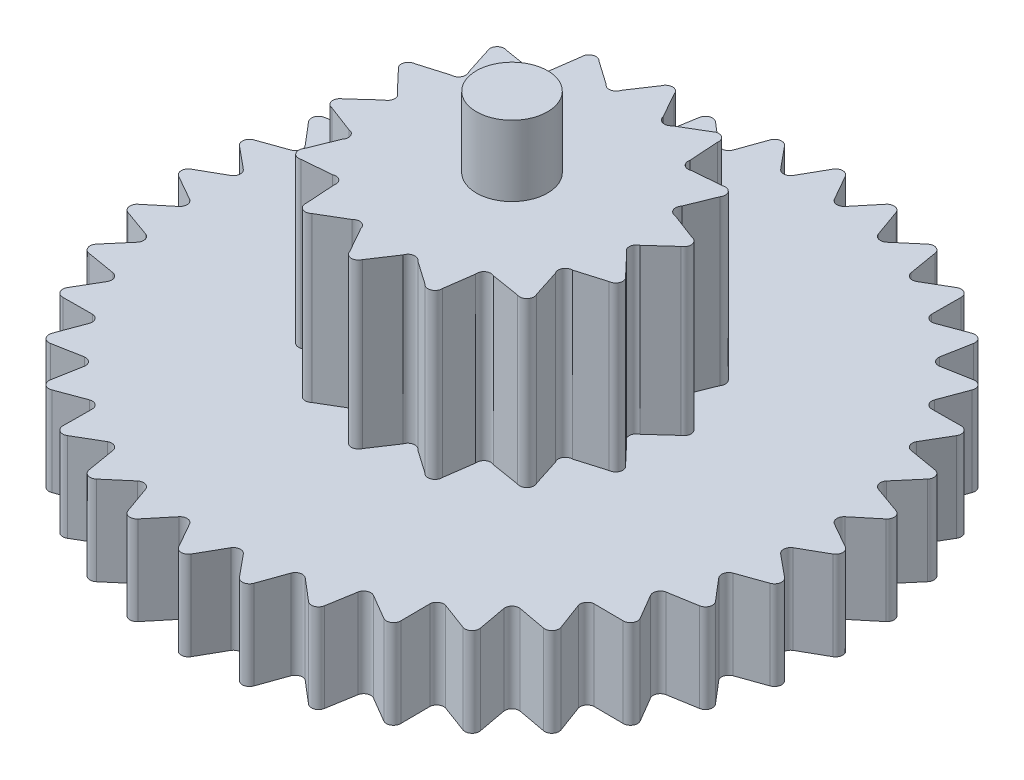
from build123d import *

# Parameters (mm, degrees)
BOSS_EXTRUDE1_DEPTH      = 2.5
SKETCH2_R                = 1
BOSS_EXTRUDE2_DEPTH      = 7.1
SKETCH3_R                = 1
BOSS_EXTRUDE3_DEPTH      = 9.08
BOSS_EXTRUDE3_DEPTH_BACK = 2.6
FILLET1_R                = 1


with BuildPart() as part:
    # Sketch1 → Boss-Extrude1 (new body)
    with BuildSketch(Plane(origin=(0, 0, 0), x_dir=(1, 0, 0), z_dir=(0, 1, 0))):
        with BuildLine():
            Line((1.42370209, 9.08258892), (0.900959127, 8.450813806))
            ThreePointArc((0.900959127, 8.450813806), (0.825205502, 8.397364753), (0.733489057, 8.383818287))
            ThreePointArc((0.733489057, 8.383818287), (0.64551831, 8.413085345), (0.580196884, 8.478876866))
            Line((0.580196884, 8.478876866), (0.175102158, 9.191827259))
            ThreePointArc((0.175102158, 9.191827259), (0, 9.295187545), (-0.175102158, 9.191827259))
            Line((-0.175102158, 9.191827259), (-0.580196884, 8.478876866))
            ThreePointArc((-0.580196884, 8.478876866), (-0.64551831, 8.413085345), (-0.733489057, 8.383818287))
            ThreePointArc((-0.733489057, 8.383818287), (-0.825205502, 8.397364753), (-0.900959127, 8.450813806))
            Line((-0.900959127, 8.450813806), (-1.42370209, 9.08258892))
            ThreePointArc((-1.42370209, 9.08258892), (-1.614092378, 9.15397276), (-1.768586015, 9.021776578))
            Line((-1.768586015, 9.021776578), (-2.043723906, 8.249313543))
            ThreePointArc((-2.043723906, 8.249313543), (-2.096628375, 8.173178596), (-2.178180478, 8.12908021))
            ThreePointArc((-2.178180478, 8.12908021), (-2.270855863, 8.126494482), (-2.35473995, 8.165977045))
            Line((-2.35473995, 8.165977045), (-2.979247871, 8.697380712))
            ThreePointArc((-2.979247871, 8.697380712), (-3.179141376, 8.734619145), (-3.308332282, 8.577603782))
            Line((-3.308332282, 8.577603782), (-3.445153411, 7.769099002))
            ThreePointArc((-3.445153411, 7.769099002), (-3.484033448, 7.684933952), (-3.556688986, 7.627344145))
            ThreePointArc((-3.556688986, 7.627344145), (-3.647507417, 7.608704788), (-3.736973192, 7.633021204))
            Line((-3.736973192, 7.633021204), (-4.444270713, 8.047906992))
            ThreePointArc((-4.444270713, 8.047906992), (-4.647593772, 8.049868547), (-4.747556546, 7.872804835))
            Line((-4.747556546, 7.872804835), (-4.741903674, 7.05282432))
            ThreePointArc((-4.741903674, 7.05282432), (-4.765577928, 6.963186478), (-4.8271293, 6.893855088))
            ThreePointArc((-4.8271293, 6.893855088), (-4.913331304, 6.85972845), (-5.005660395, 6.868139875))
            Line((-5.005660395, 6.868139875), (-5.774256638, 7.153901691))
            ThreePointArc((-5.774256638, 7.153901691), (-5.974831384, 7.120526766), (-6.042528707, 6.928794696))
            Line((-6.042528707, 6.928794696), (-5.894573592, 6.122253139))
            ThreePointArc((-5.894573592, 6.122253139), (-5.902322733, 6.029866106), (-5.950899733, 5.950899733))
            ThreePointArc((-5.950899733, 5.950899733), (-6.029866106, 5.902322733), (-6.122253139, 5.894573592))
            Line((-6.122253139, 5.894573592), (-6.928794696, 6.042528707))
            ThreePointArc((-6.928794696, 6.042528707), (-7.120526766, 5.974831384), (-7.153901691, 5.774256638))
            Line((-7.153901691, 5.774256638), (-6.868139875, 5.005660395))
            ThreePointArc((-6.868139875, 5.005660395), (-6.85972845, 4.913331304), (-6.893855088, 4.8271293))
            ThreePointArc((-6.893855088, 4.8271293), (-6.963186478, 4.765577928), (-7.05282432, 4.741903674))
            Line((-7.05282432, 4.741903674), (-7.872804835, 4.747556546))
            ThreePointArc((-7.872804835, 4.747556546), (-8.049868547, 4.647593772), (-8.047906992, 4.444270713))
            Line((-8.047906992, 4.444270713), (-7.633021204, 3.736973192))
            ThreePointArc((-7.633021204, 3.736973192), (-7.608704788, 3.647507417), (-7.627344145, 3.556688986))
            ThreePointArc((-7.627344145, 3.556688986), (-7.684933952, 3.484033448), (-7.769099002, 3.445153411))
            Line((-7.769099002, 3.445153411), (-8.577603782, 3.308332282))
            ThreePointArc((-8.577603782, 3.308332282), (-8.734619145, 3.179141376), (-8.697380712, 2.979247871))
            Line((-8.697380712, 2.979247871), (-8.165977045, 2.35473995))
            ThreePointArc((-8.165977045, 2.35473995), (-8.126494482, 2.270855863), (-8.12908021, 2.178180478))
            ThreePointArc((-8.12908021, 2.178180478), (-8.173178596, 2.096628375), (-8.249313543, 2.043723906))
            Line((-8.249313543, 2.043723906), (-9.021776578, 1.768586015))
            ThreePointArc((-9.021776578, 1.768586015), (-9.15397276, 1.614092378), (-9.08258892, 1.42370209))
            Line((-9.08258892, 1.42370209), (-8.450813806, 0.900959127))
            ThreePointArc((-8.450813806, 0.900959127), (-8.397364753, 0.825205502), (-8.383818287, 0.733489057))
            ThreePointArc((-8.383818287, 0.733489057), (-8.413085345, 0.64551831), (-8.478876866, 0.580196884))
            Line((-8.478876866, 0.580196884), (-9.191827259, 0.175102158))
            ThreePointArc((-9.191827259, 0.175102158), (-9.295187545, 0), (-9.191827259, -0.175102158))
            Line((-9.191827259, -0.175102158), (-8.478876866, -0.580196884))
            ThreePointArc((-8.478876866, -0.580196884), (-8.413085345, -0.64551831), (-8.383818287, -0.733489057))
            ThreePointArc((-8.383818287, -0.733489057), (-8.397364753, -0.825205502), (-8.450813806, -0.900959127))
            Line((-8.450813806, -0.900959127), (-9.08258892, -1.42370209))
            ThreePointArc((-9.08258892, -1.42370209), (-9.15397276, -1.614092378), (-9.021776578, -1.768586015))
            Line((-9.021776578, -1.768586015), (-8.249313543, -2.043723906))
            ThreePointArc((-8.249313543, -2.043723906), (-8.173178596, -2.096628375), (-8.12908021, -2.178180478))
            ThreePointArc((-8.12908021, -2.178180478), (-8.126494482, -2.270855863), (-8.165977045, -2.35473995))
            Line((-8.165977045, -2.35473995), (-8.697380712, -2.979247871))
            ThreePointArc((-8.697380712, -2.979247871), (-8.734619145, -3.179141376), (-8.577603782, -3.308332282))
            Line((-8.577603782, -3.308332282), (-7.769099002, -3.445153411))
            ThreePointArc((-7.769099002, -3.445153411), (-7.684933952, -3.484033448), (-7.627344145, -3.556688986))
            ThreePointArc((-7.627344145, -3.556688986), (-7.608704788, -3.647507417), (-7.633021204, -3.736973192))
            Line((-7.633021204, -3.736973192), (-8.047906992, -4.444270713))
            ThreePointArc((-8.047906992, -4.444270713), (-8.049868547, -4.647593772), (-7.872804835, -4.747556546))
            Line((-7.872804835, -4.747556546), (-7.05282432, -4.741903674))
            ThreePointArc((-7.05282432, -4.741903674), (-6.963186478, -4.765577928), (-6.893855088, -4.8271293))
            ThreePointArc((-6.893855088, -4.8271293), (-6.85972845, -4.913331304), (-6.868139875, -5.005660395))
            Line((-6.868139875, -5.005660395), (-7.153901691, -5.774256638))
            ThreePointArc((-7.153901691, -5.774256638), (-7.120526766, -5.974831384), (-6.928794696, -6.042528707))
            Line((-6.928794696, -6.042528707), (-6.122253139, -5.894573592))
            ThreePointArc((-6.122253139, -5.894573592), (-6.029866106, -5.902322733), (-5.950899733, -5.950899733))
            ThreePointArc((-5.950899733, -5.950899733), (-5.902322733, -6.029866106), (-5.894573592, -6.122253139))
            Line((-5.894573592, -6.122253139), (-6.042528707, -6.928794696))
            ThreePointArc((-6.042528707, -6.928794696), (-5.974831384, -7.120526766), (-5.774256638, -7.153901691))
            Line((-5.774256638, -7.153901691), (-5.005660395, -6.868139875))
            ThreePointArc((-5.005660395, -6.868139875), (-4.913331304, -6.85972845), (-4.8271293, -6.893855088))
            ThreePointArc((-4.8271293, -6.893855088), (-4.765577928, -6.963186478), (-4.741903674, -7.05282432))
            Line((-4.741903674, -7.05282432), (-4.747556546, -7.872804835))
            ThreePointArc((-4.747556546, -7.872804835), (-4.647593772, -8.049868547), (-4.444270713, -8.047906992))
            Line((-4.444270713, -8.047906992), (-3.736973192, -7.633021204))
            ThreePointArc((-3.736973192, -7.633021204), (-3.647507417, -7.608704788), (-3.556688986, -7.627344145))
            ThreePointArc((-3.556688986, -7.627344145), (-3.484033448, -7.684933952), (-3.445153411, -7.769099002))
            Line((-3.445153411, -7.769099002), (-3.308332282, -8.577603782))
            ThreePointArc((-3.308332282, -8.577603782), (-3.179141376, -8.734619145), (-2.979247871, -8.697380712))
            Line((-2.979247871, -8.697380712), (-2.35473995, -8.165977045))
            ThreePointArc((-2.35473995, -8.165977045), (-2.270855863, -8.126494482), (-2.178180478, -8.12908021))
            ThreePointArc((-2.178180478, -8.12908021), (-2.096628375, -8.173178596), (-2.043723906, -8.249313543))
            Line((-2.043723906, -8.249313543), (-1.768586015, -9.021776578))
            ThreePointArc((-1.768586015, -9.021776578), (-1.614092378, -9.15397276), (-1.42370209, -9.08258892))
            Line((-1.42370209, -9.08258892), (-0.900959127, -8.450813806))
            ThreePointArc((-0.900959127, -8.450813806), (-0.825205502, -8.397364753), (-0.733489057, -8.383818287))
            ThreePointArc((-0.733489057, -8.383818287), (-0.64551831, -8.413085345), (-0.580196884, -8.478876866))
            Line((-0.580196884, -8.478876866), (-0.175102158, -9.191827259))
            ThreePointArc((-0.175102158, -9.191827259), (0, -9.295187545), (0.175102158, -9.191827259))
            Line((0.175102158, -9.191827259), (0.580196884, -8.478876866))
            ThreePointArc((0.580196884, -8.478876866), (0.64551831, -8.413085345), (0.733489057, -8.383818287))
            ThreePointArc((0.733489057, -8.383818287), (0.825205502, -8.397364753), (0.900959127, -8.450813806))
            Line((0.900959127, -8.450813806), (1.42370209, -9.08258892))
            ThreePointArc((1.42370209, -9.08258892), (1.614092378, -9.15397276), (1.768586015, -9.021776578))
            Line((1.768586015, -9.021776578), (2.043723906, -8.249313543))
            ThreePointArc((2.043723906, -8.249313543), (2.096628375, -8.173178596), (2.178180478, -8.12908021))
            ThreePointArc((2.178180478, -8.12908021), (2.270855863, -8.126494482), (2.35473995, -8.165977045))
            Line((2.35473995, -8.165977045), (2.979247871, -8.697380712))
            ThreePointArc((2.979247871, -8.697380712), (3.179141376, -8.734619145), (3.308332282, -8.577603782))
            Line((3.308332282, -8.577603782), (3.445153411, -7.769099002))
            ThreePointArc((3.445153411, -7.769099002), (3.484033448, -7.684933952), (3.556688986, -7.627344145))
            ThreePointArc((3.556688986, -7.627344145), (3.647507417, -7.608704788), (3.736973192, -7.633021204))
            Line((3.736973192, -7.633021204), (4.444270713, -8.047906992))
            ThreePointArc((4.444270713, -8.047906992), (4.647593772, -8.049868547), (4.747556546, -7.872804835))
            Line((4.747556546, -7.872804835), (4.741903674, -7.05282432))
            ThreePointArc((4.741903674, -7.05282432), (4.765577928, -6.963186478), (4.8271293, -6.893855088))
            ThreePointArc((4.8271293, -6.893855088), (4.913331304, -6.85972845), (5.005660395, -6.868139875))
            Line((5.005660395, -6.868139875), (5.774256638, -7.153901691))
            ThreePointArc((5.774256638, -7.153901691), (5.974831384, -7.120526766), (6.042528707, -6.928794696))
            Line((6.042528707, -6.928794696), (5.894573592, -6.122253139))
            ThreePointArc((5.894573592, -6.122253139), (5.902322733, -6.029866106), (5.950899733, -5.950899733))
            ThreePointArc((5.950899733, -5.950899733), (6.029866106, -5.902322733), (6.122253139, -5.894573592))
            Line((6.122253139, -5.894573592), (6.928794696, -6.042528707))
            ThreePointArc((6.928794696, -6.042528707), (7.120526766, -5.974831384), (7.153901691, -5.774256638))
            Line((7.153901691, -5.774256638), (6.868139875, -5.005660395))
            ThreePointArc((6.868139875, -5.005660395), (6.85972845, -4.913331304), (6.893855088, -4.8271293))
            ThreePointArc((6.893855088, -4.8271293), (6.963186478, -4.765577928), (7.05282432, -4.741903674))
            Line((7.05282432, -4.741903674), (7.872804835, -4.747556546))
            ThreePointArc((7.872804835, -4.747556546), (8.049868547, -4.647593772), (8.047906992, -4.444270713))
            Line((8.047906992, -4.444270713), (7.633021204, -3.736973192))
            ThreePointArc((7.633021204, -3.736973192), (7.608704788, -3.647507417), (7.627344145, -3.556688986))
            ThreePointArc((7.627344145, -3.556688986), (7.684933952, -3.484033448), (7.769099002, -3.445153411))
            Line((7.769099002, -3.445153411), (8.577603782, -3.308332282))
            ThreePointArc((8.577603782, -3.308332282), (8.734619145, -3.179141376), (8.697380712, -2.979247871))
            Line((8.697380712, -2.979247871), (8.165977045, -2.35473995))
            ThreePointArc((8.165977045, -2.35473995), (8.126494482, -2.270855863), (8.12908021, -2.178180478))
            ThreePointArc((8.12908021, -2.178180478), (8.173178596, -2.096628375), (8.249313543, -2.043723906))
            Line((8.249313543, -2.043723906), (9.021776578, -1.768586015))
            ThreePointArc((9.021776578, -1.768586015), (9.15397276, -1.614092378), (9.08258892, -1.42370209))
            Line((9.08258892, -1.42370209), (8.450813806, -0.900959127))
            ThreePointArc((8.450813806, -0.900959127), (8.397364753, -0.825205502), (8.383818287, -0.733489057))
            ThreePointArc((8.383818287, -0.733489057), (8.413085345, -0.64551831), (8.478876866, -0.580196884))
            Line((8.478876866, -0.580196884), (9.191827259, -0.175102158))
            ThreePointArc((9.191827259, -0.175102158), (9.295187545, 0), (9.191827259, 0.175102158))
            Line((9.191827259, 0.175102158), (8.478876866, 0.580196884))
            ThreePointArc((8.478876866, 0.580196884), (8.413085345, 0.64551831), (8.383818287, 0.733489057))
            ThreePointArc((8.383818287, 0.733489057), (8.397364753, 0.825205502), (8.450813806, 0.900959127))
            Line((8.450813806, 0.900959127), (9.08258892, 1.42370209))
            ThreePointArc((9.08258892, 1.42370209), (9.15397276, 1.614092378), (9.021776578, 1.768586015))
            Line((9.021776578, 1.768586015), (8.249313543, 2.043723906))
            ThreePointArc((8.249313543, 2.043723906), (8.173178596, 2.096628375), (8.12908021, 2.178180478))
            ThreePointArc((8.12908021, 2.178180478), (8.126494482, 2.270855863), (8.165977045, 2.35473995))
            Line((8.165977045, 2.35473995), (8.697380712, 2.979247871))
            ThreePointArc((8.697380712, 2.979247871), (8.734619145, 3.179141376), (8.577603782, 3.308332282))
            Line((8.577603782, 3.308332282), (7.769099002, 3.445153411))
            ThreePointArc((7.769099002, 3.445153411), (7.684933952, 3.484033448), (7.627344145, 3.556688986))
            ThreePointArc((7.627344145, 3.556688986), (7.608704788, 3.647507417), (7.633021204, 3.736973192))
            Line((7.633021204, 3.736973192), (8.047906992, 4.444270713))
            ThreePointArc((8.047906992, 4.444270713), (8.049868547, 4.647593772), (7.872804835, 4.747556546))
            Line((7.872804835, 4.747556546), (7.05282432, 4.741903674))
            ThreePointArc((7.05282432, 4.741903674), (6.963186478, 4.765577928), (6.893855088, 4.8271293))
            ThreePointArc((6.893855088, 4.8271293), (6.85972845, 4.913331304), (6.868139875, 5.005660395))
            Line((6.868139875, 5.005660395), (7.153901691, 5.774256638))
            ThreePointArc((7.153901691, 5.774256638), (7.120526766, 5.974831384), (6.928794696, 6.042528707))
            Line((6.928794696, 6.042528707), (6.122253139, 5.894573592))
            ThreePointArc((6.122253139, 5.894573592), (6.029866106, 5.902322733), (5.950899733, 5.950899733))
            ThreePointArc((5.950899733, 5.950899733), (5.902322733, 6.029866106), (5.894573592, 6.122253139))
            Line((5.894573592, 6.122253139), (6.042528707, 6.928794696))
            ThreePointArc((6.042528707, 6.928794696), (5.974831384, 7.120526766), (5.774256638, 7.153901691))
            Line((5.774256638, 7.153901691), (5.005660395, 6.868139875))
            ThreePointArc((5.005660395, 6.868139875), (4.913331304, 6.85972845), (4.8271293, 6.893855088))
            ThreePointArc((4.8271293, 6.893855088), (4.765577928, 6.963186478), (4.741903674, 7.05282432))
            Line((4.741903674, 7.05282432), (4.747556546, 7.872804835))
            ThreePointArc((4.747556546, 7.872804835), (4.647593772, 8.049868547), (4.444270713, 8.047906992))
            Line((4.444270713, 8.047906992), (3.736973192, 7.633021204))
            ThreePointArc((3.736973192, 7.633021204), (3.647507417, 7.608704788), (3.556688986, 7.627344145))
            ThreePointArc((3.556688986, 7.627344145), (3.484033448, 7.684933952), (3.445153411, 7.769099002))
            Line((3.445153411, 7.769099002), (3.308332282, 8.577603782))
            ThreePointArc((3.308332282, 8.577603782), (3.179141376, 8.734619145), (2.979247871, 8.697380712))
            Line((2.979247871, 8.697380712), (2.35473995, 8.165977045))
            ThreePointArc((2.35473995, 8.165977045), (2.270855863, 8.126494482), (2.178180478, 8.12908021))
            ThreePointArc((2.178180478, 8.12908021), (2.096628375, 8.173178596), (2.043723906, 8.249313543))
            Line((2.043723906, 8.249313543), (1.768586015, 9.021776578))
            ThreePointArc((1.768586015, 9.021776578), (1.614092378, 9.15397276), (1.42370209, 9.08258892))
        make_face()
        with BuildLine():
            Line((0.363616578, 4.195562504), (0.765952697, 3.481051729))
            ThreePointArc((0.765952697, 3.481051729), (0.90947817, 3.327320894), (1.111157569, 3.386971134))
            Line((1.111157569, 3.386971134), (1.816711653, 3.804814927))
            ThreePointArc((1.816711653, 3.804814927), (2.048025087, 3.832777854), (2.148849009, 3.622724606))
            Line((2.148849009, 3.622724606), (2.20132672, 2.804405543))
            ThreePointArc((2.20132672, 2.804405543), (2.263937393, 2.603625477), (2.471525522, 2.569863076))
            Line((2.471525522, 2.569863076), (3.288503414, 2.64019888))
            ThreePointArc((3.288503414, 2.64019888), (3.509042276, 2.56502947), (3.508742802, 2.332032172))
            Line((3.508742802, 2.332032172), (3.200968251, 1.571982947))
            ThreePointArc((3.200968251, 1.571982947), (3.170263313, 1.363920605), (3.342644798, 1.243432619))
            Line((3.342644798, 1.243432619), (4.109234005, 0.952329567))
            ThreePointArc((4.109234005, 0.952329567), (4.27531787, 0.788916042), (4.173954314, 0.579122668))
            Line((4.173954314, 0.579122668), (3.566886025, 0.02788035))
            ThreePointArc((3.566886025, 0.02788035), (3.448946966, -0.146254969), (3.551979538, -0.329604417))
            Line((3.551979538, -0.329604417), (4.116347668, -0.924489795))
            ThreePointArc((4.116347668, -0.924489795), (4.195081588, -1.143781382), (4.012730247, -1.288818683))
            Line((4.012730247, -1.288818683), (3.22660554, -1.52207379))
            ThreePointArc((3.22660554, -1.52207379), (3.044791636, -1.627792451), (3.058068432, -1.837688754))
            Line((3.058068432, -1.837688754), (3.308435455, -2.618532114))
            ThreePointArc((3.308435455, -2.618532114), (3.284225212, -2.850268375), (3.057003004, -2.901823185))
            Line((3.057003004, -2.901823185), (2.247523519, -2.770892048))
            ThreePointArc((2.247523519, -2.770892048), (2.037845243, -2.787255174), (1.958736631, -2.982125794))
            Line((1.958736631, -2.982125794), (1.845514287, -3.794271533))
            ThreePointArc((1.845514287, -3.794271533), (1.723155017, -3.992554258), (1.496066087, -3.940415516))
            Line((1.496066087, -3.940415516), (0.823559163, -3.471230652))
            ThreePointArc((0.823559163, -3.471230652), (0.62754587, -3.394997325), (0.47172028, -3.536245746))
            Line((0.47172028, -3.536245746), (0.017333643, -4.218838439))
            ThreePointArc((0.017333643, -4.218838439), (-0.1789399, -4.344395304), (-0.360917804, -4.198889727))
            Line((-0.360917804, -4.198889727), (-0.763253923, -3.484378952))
            ThreePointArc((-0.763253923, -3.484378952), (-0.906779396, -3.330648117), (-1.108458795, -3.390298358))
            Line((-1.108458795, -3.390298358), (-1.814012878, -3.80814215))
            ThreePointArc((-1.814012878, -3.80814215), (-2.045326313, -3.836105078), (-2.146150234, -3.62605183))
            Line((-2.146150234, -3.62605183), (-2.198627945, -2.807732766))
            ThreePointArc((-2.198627945, -2.807732766), (-2.261238619, -2.606952701), (-2.468826748, -2.573190299))
            Line((-2.468826748, -2.573190299), (-3.285804639, -2.643526104))
            ThreePointArc((-3.285804639, -2.643526104), (-3.506343502, -2.568356693), (-3.506044028, -2.335359396))
            Line((-3.506044028, -2.335359396), (-3.198269477, -1.57531017))
            ThreePointArc((-3.198269477, -1.57531017), (-3.167564539, -1.367247829), (-3.339946023, -1.246759842))
            Line((-3.339946023, -1.246759842), (-4.106535231, -0.95565679))
            ThreePointArc((-4.106535231, -0.95565679), (-4.272619095, -0.792243265), (-4.17125554, -0.582449891))
            Line((-4.17125554, -0.582449891), (-3.564187251, -0.031207573))
            ThreePointArc((-3.564187251, -0.031207573), (-3.446248191, 0.142927745), (-3.549280764, 0.326277193))
            Line((-3.549280764, 0.326277193), (-4.113648894, 0.921162572))
            ThreePointArc((-4.113648894, 0.921162572), (-4.192382814, 1.140454159), (-4.010031473, 1.285491459))
            Line((-4.010031473, 1.285491459), (-3.223906766, 1.518746567))
            ThreePointArc((-3.223906766, 1.518746567), (-3.042092861, 1.624465228), (-3.055369658, 1.83436153))
            Line((-3.055369658, 1.83436153), (-3.30573668, 2.615204891))
            ThreePointArc((-3.30573668, 2.615204891), (-3.281526438, 2.846941151), (-3.05430423, 2.898495962))
            Line((-3.05430423, 2.898495962), (-2.244824744, 2.767564825))
            ThreePointArc((-2.244824744, 2.767564825), (-2.035146469, 2.783927951), (-1.956037856, 2.978798571))
            Line((-1.956037856, 2.978798571), (-1.842815512, 3.790944309))
            ThreePointArc((-1.842815512, 3.790944309), (-1.720456242, 3.989227035), (-1.493367313, 3.937088293))
            Line((-1.493367313, 3.937088293), (-0.820860388, 3.467903429))
            ThreePointArc((-0.820860388, 3.467903429), (-0.624847096, 3.391670101), (-0.469021506, 3.532918523))
            Line((-0.469021506, 3.532918523), (-0.014634869, 4.215511215))
            ThreePointArc((-0.014634869, 4.215511215), (0.181638675, 4.341068081), (0.363616578, 4.195562504))
        make_face(mode=Mode.SUBTRACT)
    extrude(amount=BOSS_EXTRUDE1_DEPTH)

    # Sketch2 → Boss-Extrude2 (add)
    with BuildSketch(Plane(origin=(0, 0, 0), x_dir=(1, 0, 0), z_dir=(0, 1, 0))):
        with BuildLine():
            Line((-4.010031473, 1.285491459), (-3.223906766, 1.518746567))
            ThreePointArc((-3.223906766, 1.518746567), (-3.042092861, 1.624465228), (-3.055369658, 1.83436153))
            Line((-3.055369658, 1.83436153), (-3.30573668, 2.615204891))
            ThreePointArc((-3.30573668, 2.615204891), (-3.281526438, 2.846941151), (-3.05430423, 2.898495962))
            Line((-3.05430423, 2.898495962), (-2.244824744, 2.767564825))
            ThreePointArc((-2.244824744, 2.767564825), (-2.035146469, 2.783927951), (-1.956037856, 2.978798571))
            Line((-1.956037856, 2.978798571), (-1.842815512, 3.790944309))
            ThreePointArc((-1.842815512, 3.790944309), (-1.720456242, 3.989227035), (-1.493367313, 3.937088293))
            Line((-1.493367313, 3.937088293), (-0.820860388, 3.467903429))
            ThreePointArc((-0.820860388, 3.467903429), (-0.624847096, 3.391670101), (-0.469021506, 3.532918523))
            Line((-0.469021506, 3.532918523), (-0.014634869, 4.215511215))
            ThreePointArc((-0.014634869, 4.215511215), (0.181638675, 4.341068081), (0.363616578, 4.195562504))
            Line((0.363616578, 4.195562504), (0.765952697, 3.481051729))
            ThreePointArc((0.765952697, 3.481051729), (0.90947817, 3.327320894), (1.111157569, 3.386971134))
            Line((1.111157569, 3.386971134), (1.816711653, 3.804814927))
            ThreePointArc((1.816711653, 3.804814927), (2.048025087, 3.832777854), (2.148849009, 3.622724606))
            Line((2.148849009, 3.622724606), (2.20132672, 2.804405543))
            ThreePointArc((2.20132672, 2.804405543), (2.263937393, 2.603625477), (2.471525522, 2.569863076))
            Line((2.471525522, 2.569863076), (3.288503414, 2.64019888))
            ThreePointArc((3.288503414, 2.64019888), (3.509042276, 2.56502947), (3.508742802, 2.332032172))
            Line((3.508742802, 2.332032172), (3.200968251, 1.571982947))
            ThreePointArc((3.200968251, 1.571982947), (3.170263313, 1.363920605), (3.342644798, 1.243432619))
            Line((3.342644798, 1.243432619), (4.109234005, 0.952329567))
            ThreePointArc((4.109234005, 0.952329567), (4.27531787, 0.788916042), (4.173954314, 0.579122668))
            Line((4.173954314, 0.579122668), (3.566886025, 0.02788035))
            ThreePointArc((3.566886025, 0.02788035), (3.448946966, -0.146254969), (3.551979538, -0.329604417))
            Line((3.551979538, -0.329604417), (4.116347668, -0.924489795))
            ThreePointArc((4.116347668, -0.924489795), (4.195081588, -1.143781382), (4.012730247, -1.288818683))
            Line((4.012730247, -1.288818683), (3.22660554, -1.52207379))
            ThreePointArc((3.22660554, -1.52207379), (3.044791636, -1.627792451), (3.058068432, -1.837688754))
            Line((3.058068432, -1.837688754), (3.308435455, -2.618532114))
            ThreePointArc((3.308435455, -2.618532114), (3.284225212, -2.850268375), (3.057003004, -2.901823185))
            Line((3.057003004, -2.901823185), (2.247523519, -2.770892048))
            ThreePointArc((2.247523519, -2.770892048), (2.037845243, -2.787255174), (1.958736631, -2.982125794))
            Line((1.958736631, -2.982125794), (1.845514287, -3.794271533))
            ThreePointArc((1.845514287, -3.794271533), (1.723155017, -3.992554258), (1.496066087, -3.940415516))
            Line((1.496066087, -3.940415516), (0.823559163, -3.471230652))
            ThreePointArc((0.823559163, -3.471230652), (0.62754587, -3.394997325), (0.47172028, -3.536245746))
            Line((0.47172028, -3.536245746), (0.017333643, -4.218838439))
            ThreePointArc((0.017333643, -4.218838439), (-0.1789399, -4.344395304), (-0.360917804, -4.198889727))
            Line((-0.360917804, -4.198889727), (-0.763253923, -3.484378952))
            ThreePointArc((-0.763253923, -3.484378952), (-0.906779396, -3.330648117), (-1.108458795, -3.390298358))
            Line((-1.108458795, -3.390298358), (-1.814012878, -3.80814215))
            ThreePointArc((-1.814012878, -3.80814215), (-2.045326313, -3.836105078), (-2.146150234, -3.62605183))
            Line((-2.146150234, -3.62605183), (-2.198627945, -2.807732766))
            ThreePointArc((-2.198627945, -2.807732766), (-2.261238619, -2.606952701), (-2.468826748, -2.573190299))
            Line((-2.468826748, -2.573190299), (-3.285804639, -2.643526104))
            ThreePointArc((-3.285804639, -2.643526104), (-3.506343502, -2.568356693), (-3.506044028, -2.335359396))
            Line((-3.506044028, -2.335359396), (-3.198269477, -1.57531017))
            ThreePointArc((-3.198269477, -1.57531017), (-3.167564539, -1.367247829), (-3.339946023, -1.246759842))
            Line((-3.339946023, -1.246759842), (-4.106535231, -0.95565679))
            ThreePointArc((-4.106535231, -0.95565679), (-4.272619095, -0.792243265), (-4.17125554, -0.582449891))
            Line((-4.17125554, -0.582449891), (-3.564187251, -0.031207573))
            ThreePointArc((-3.564187251, -0.031207573), (-3.446248191, 0.142927745), (-3.549280764, 0.326277193))
            Line((-3.549280764, 0.326277193), (-4.113648894, 0.921162572))
            ThreePointArc((-4.113648894, 0.921162572), (-4.192382814, 1.140454159), (-4.010031473, 1.285491459))
        make_face()
        Circle(SKETCH2_R, mode=Mode.SUBTRACT)
    extrude(amount=BOSS_EXTRUDE2_DEPTH)

    # Sketch3 → Boss-Extrude3 (add, two sides)
    with BuildSketch(Plane(origin=(0, 0, 0), x_dir=(1, 0, 0), z_dir=(0, 1, 0))) as boss_extrude3_sk:
        Circle(SKETCH3_R)
    extrude(amount=BOSS_EXTRUDE3_DEPTH)
    extrude(boss_extrude3_sk.sketch, amount=-BOSS_EXTRUDE3_DEPTH_BACK)

    # Fillet1
    fillet1_edges = [part.edges().sort_by_distance(p)[0] for p in [
        (-1, -2.6, 0),
    ]]
    fillet(fillet1_edges, radius=FILLET1_R)


solid = part.part
